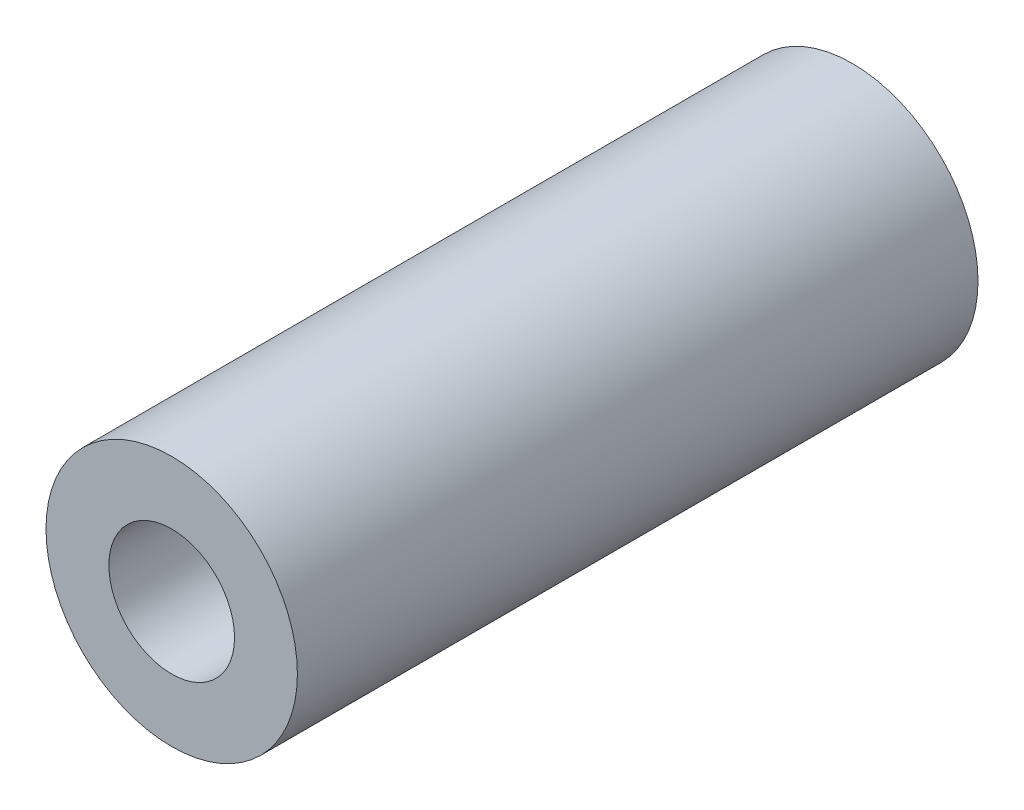
from build123d import *

# Parameters (mm, degrees)
SKETCH2_R           = 6.35
SKETCH2_R_2         = 3.175
BOSS_EXTRUDE1_DEPTH = 34.383424502


with BuildPart() as part:
    # Sketch2 → Boss-Extrude1 (new body)
    with BuildSketch(Plane.XY):
        Circle(SKETCH2_R)
        Circle(SKETCH2_R_2, mode=Mode.SUBTRACT)
    extrude(amount=BOSS_EXTRUDE1_DEPTH)


solid = part.part
